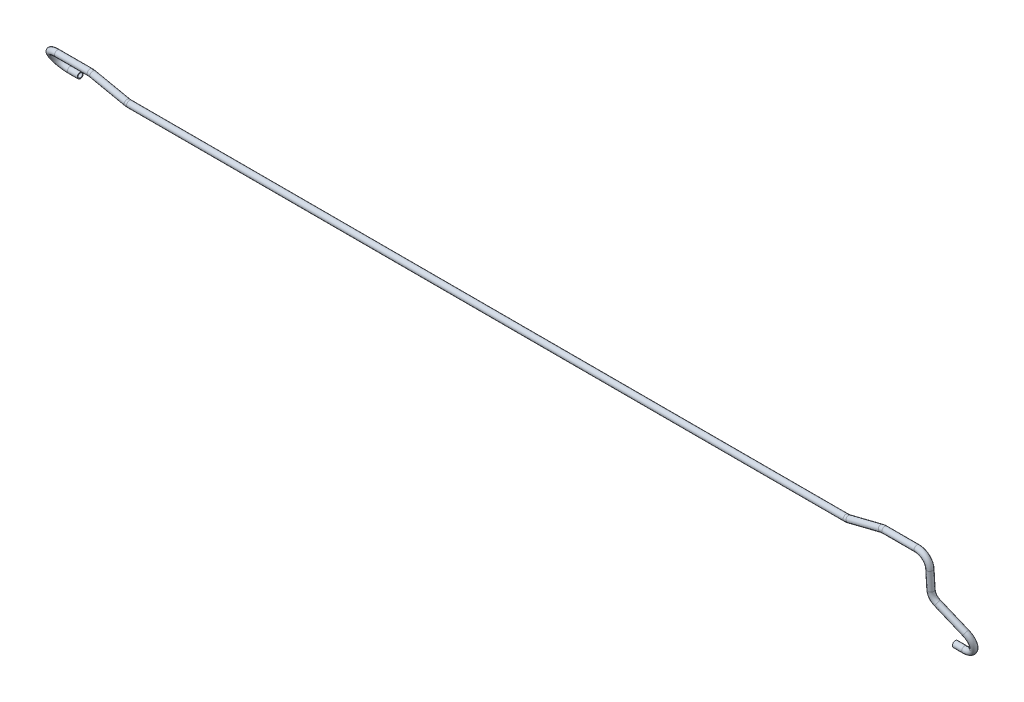
from build123d import *

# Parameters (mm, degrees)
SKETCH1_R   = 8
SKETCH1_R_2 = 6


with BuildPart() as part:
    # Sweep1: sweep along a curve in space
    with BuildLine() as sweep1_path:
        Line((0, 0, 0), (25.328315974, 0, 0))
        ThreePointArc((25.328315974, 0, 0), (56.655912303, 21.705280356, 6.395305819), (45.021337144, 57.054842292, 16.810801747))
        Line((-18.378395213, 102.28267684, 30.13686014), (45.021337144, 57.054842292, 16.810801747))
        ThreePointArc((-18.378395213, 102.28267684, 30.13686014), (-28.394954518, 113.912892898, 32.511330292), (-32, 128.945157365, 34.016709442))
        Line((-32, 128.945157365, 34.016709442), (-32, 179.0592401, 37.023554406))
        ThreePointArc((-32, 179.0592401, 37.023554406), (-41.665476221, 202.351874803, 38.421112488), (-65, 212, 39))
        Line((-65, 212, 39), (-152.422876628, 212, 39))
        ThreePointArc((-152.422876628, 212, 39), (-156.956598136, 211.690227584, 38.955746798), (-161.404339018, 210.766785075, 38.823826439))
        Line((-252.595660982, 185.233214925, 35.176173561), (-161.404339018, 210.766785075, 38.823826439))
        ThreePointArc((-252.595660982, 185.233214925, 35.176173561), (-257.043401864, 184.309772416, 35.044253202), (-261.577123372, 184, 35))
        Line((-261.577123372, 184, 35), (-2207.072381803, 184, 35))
        ThreePointArc((-2213.854450534, 184.704434612, 35), (-2210.481659013, 184.176581091, 35), (-2207.072381803, 184, 35))
        Line((-2307.145549466, 204.295565388, 35), (-2213.854450534, 184.704434612, 35))
        ThreePointArc((-2313.927618197, 205, 35), (-2310.518340987, 204.823418909, 35), (-2307.145549466, 204.295565388, 35))
        Line((-2402.5, 205, 35), (-2313.927618197, 205, 35))
        ThreePointArc((-2402.5, 205, 35), (-2435.5, 177.022330333, 17.5), (-2402.5, 149.044660666, 0))
        Line((-2402.5, 149.044660666, 0), (-2375.5, 149.044660666, 0))
    # Sketch1 → Sweep1 (sweep)
    with BuildSketch(Plane(origin=(0, 0, 0), x_dir=(0, 0, -1), z_dir=(1, 0, 0))):
        Circle(SKETCH1_R)
        Circle(SKETCH1_R_2, mode=Mode.SUBTRACT)
    sweep(path=sweep1_path.line)


solid = part.part
